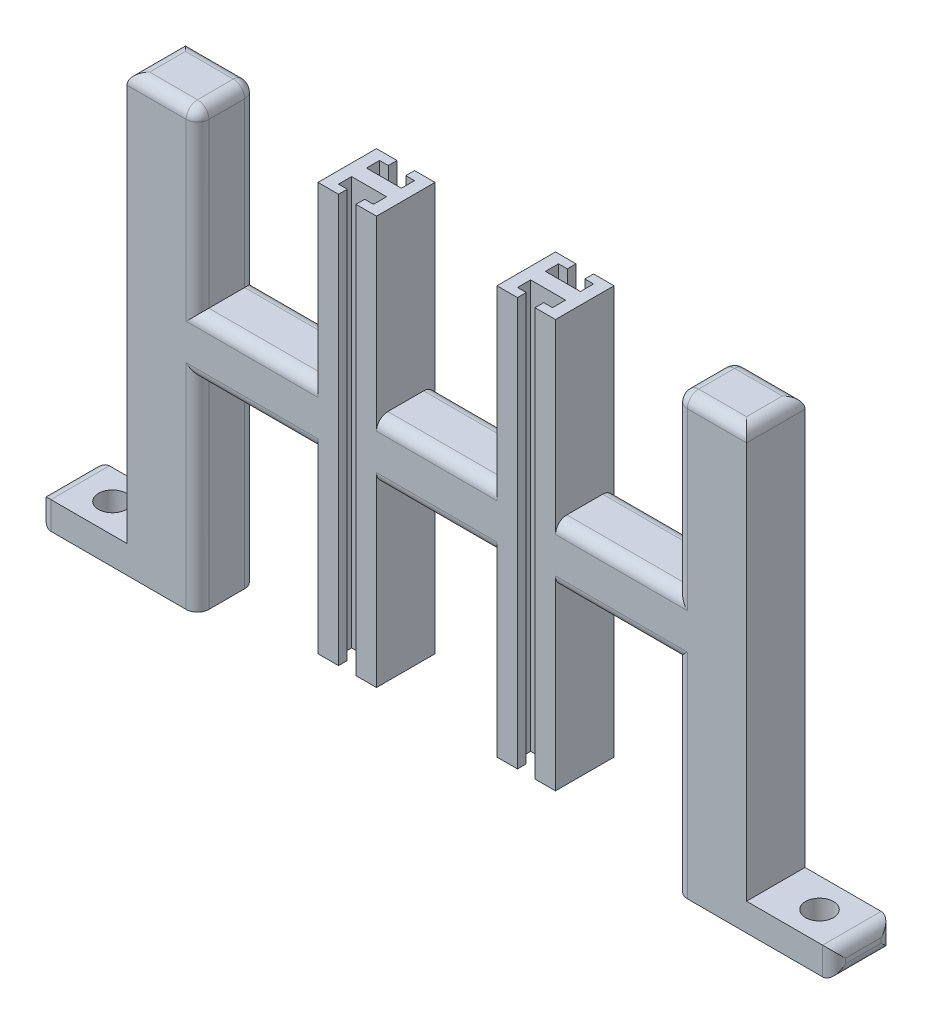
from build123d import *

# Parameters (mm, degrees)
SKETCH1_W                = 90
SKETCH1_H                = 8.5
BOSS_EXTRUDE1_DEPTH      = 8.5
SKETCH2_W                = 8.5
SKETCH2_H                = 8.5
BOSS_EXTRUDE2_DEPTH      = 25.4
BOSS_EXTRUDE2_DEPTH_BACK = 33.9
SKETCH3_W                = 10.25
SKETCH3_H                = 8.5
BOSS_EXTRUDE3_DEPTH      = 25.4
BOSS_EXTRUDE3_DEPTH_BACK = 37.900000018
SKETCH4_W                = 8.5
SKETCH4_H                = 4
BOSS_EXTRUDE4_DEPTH      = 12.7
SKETCH5_W                = 8.5
SKETCH5_H                = 4
BOSS_EXTRUDE5_DEPTH      = 12.7
SKETCH6_R                = 2.032
CUT_EXTRUDE1_DEPTH       = 12.7
CUT_EXTRUDE2_DEPTH       = 9.906
CUT_EXTRUDE2_DEPTH_BACK  = 73.406
FILLET2_R                = 1.651


with BuildPart() as part:
    # Sketch1 → Boss-Extrude1 (new body)
    with BuildSketch(Plane.XY):
        Rectangle(SKETCH1_W, SKETCH1_H)
    extrude(amount=BOSS_EXTRUDE1_DEPTH)

    # Sketch2 → Boss-Extrude2 (add, two sides)
    with BuildSketch(Plane(origin=(0, 4.25, 0), x_dir=(1, 0, 0), z_dir=(0, 1, 0))) as boss_extrude2_sk:
        with Locations((13, -4.25)):
            Rectangle(SKETCH2_W, SKETCH2_H)
        with Locations((-13, -4.25)):
            Rectangle(SKETCH2_W, SKETCH2_H)
    extrude(amount=BOSS_EXTRUDE2_DEPTH)
    extrude(boss_extrude2_sk.sketch, amount=-BOSS_EXTRUDE2_DEPTH_BACK)

    # Sketch3 → Boss-Extrude3 (add, two sides)
    with BuildSketch(Plane(origin=(0, 4.25, 0), x_dir=(1, 0, 0), z_dir=(0, 1, 0))) as boss_extrude3_sk:
        with Locations((-39.875, -4.25)):
            Rectangle(SKETCH3_W, SKETCH3_H)
        with Locations((39.875, -4.25)):
            Rectangle(SKETCH3_W, SKETCH3_H)
    extrude(amount=BOSS_EXTRUDE3_DEPTH)
    extrude(boss_extrude3_sk.sketch, amount=-BOSS_EXTRUDE3_DEPTH_BACK)

    # Sketch4 → Boss-Extrude4 (add)
    with BuildSketch(Plane(origin=(45, 0, 0), x_dir=(0, 0, -1), z_dir=(1, 0, 0))):
        with Locations((-4.25, -31.650000018)):
            Rectangle(SKETCH4_W, SKETCH4_H)
    extrude(amount=BOSS_EXTRUDE4_DEPTH)

    # Sketch5 → Boss-Extrude5 (add)
    with BuildSketch(Plane.ZY.offset(45)):
        with Locations((4.25, -31.650000018)):
            Rectangle(SKETCH5_W, SKETCH5_H)
    extrude(amount=BOSS_EXTRUDE5_DEPTH)

    # Sketch6 → Cut-Extrude1 (cut)
    with BuildSketch(Plane(origin=(0, -29.650000018, 0), x_dir=(1, 0, 0), z_dir=(0, 1, 0))):
        with Locations((51.35, -4.25)):
            Circle(SKETCH6_R)
        with Locations((-51.35, -4.25)):
            Circle(SKETCH6_R)
    extrude(amount=-CUT_EXTRUDE1_DEPTH, mode=Mode.SUBTRACT)

    # Sketch7 → Cut-Extrude2 (cut, two sides)
    with BuildSketch(Plane(origin=(0, 29.65, 0), x_dir=(1, 0, 0), z_dir=(0, 1, 0))) as cut_extrude2_sk:
        Polygon((14.27, 0), (14.27, -1.27), (15.54, -1.27), (15.54, -3.175), (10.46, -3.175), (10.46, -1.27), (11.73, -1.27), (11.73, 0), align=None)
        Polygon((-11.73, -1.27), (-11.73, 0), (-14.27, 0), (-14.27, -1.27), (-15.54, -1.27), (-15.54, -3.175), (-10.46, -3.175), (-10.46, -1.27), align=None)
        Polygon((-14.27, -8.5), (-14.27, -7.23), (-15.54, -7.23), (-15.54, -5.325), (-10.46, -5.325), (-10.46, -7.23), (-11.73, -7.23), (-11.73, -8.5), align=None)
        Polygon((11.73, -7.23), (11.73, -8.5), (14.27, -8.5), (14.27, -7.23), (15.54, -7.23), (15.54, -5.325), (10.46, -5.325), (10.46, -7.23), align=None)
    extrude(amount=CUT_EXTRUDE2_DEPTH, mode=Mode.SUBTRACT)
    extrude(cut_extrude2_sk.sketch, amount=-CUT_EXTRUDE2_DEPTH_BACK, mode=Mode.SUBTRACT)

    # Fillet2
    fillet2_edges = [part.edges().sort_by_distance(p)[0] for p in [
        (57.7, -31.650000018, 8.5),
        (57.7, -33.650000018, 4.25),
        (57.7, -31.650000018, 0),
        (57.7, -29.650000018, 4.25),
        (-57.7, -31.650000018, 8.5),
        (-57.7, -29.650000018, 4.25),
        (-57.7, -31.650000018, 0),
        (-57.7, -33.650000018, 4.25),
        (26, -4.25, 0),
        (0, 4.25, 0),
        (0, 4.25, 8.5),
        (26, -4.25, 8.5),
        (0, -4.25, 0),
        (-26, 4.25, 0),
        (-26, 4.25, 8.5),
        (0, -4.25, 8.5),
        (-26, -4.25, 0),
        (-26, -4.25, 8.5),
        (-34.75, 16.95, 8.5),
        (-34.75, -18.950000009, 8.5),
        (-34.75, 16.95, 0),
        (-34.75, -18.950000009, 0),
        (-39.875, 29.65, 0),
        (-45, 29.65, 4.25),
        (-39.875, 29.65, 8.5),
        (-34.75, 29.65, 4.25),
        (26, 4.25, 0),
        (26, 4.25, 8.5),
        (34.75, 16.95, 0),
        (34.75, -18.950000009, 0),
        (34.75, 16.95, 8.5),
        (34.75, -18.950000009, 8.5),
        (39.875, 29.65, 0),
        (34.75, 29.65, 4.25),
        (39.875, 29.65, 8.5),
        (45, 29.65, 4.25),
    ]]
    fillet(fillet2_edges, radius=FILLET2_R)


solid = part.part
